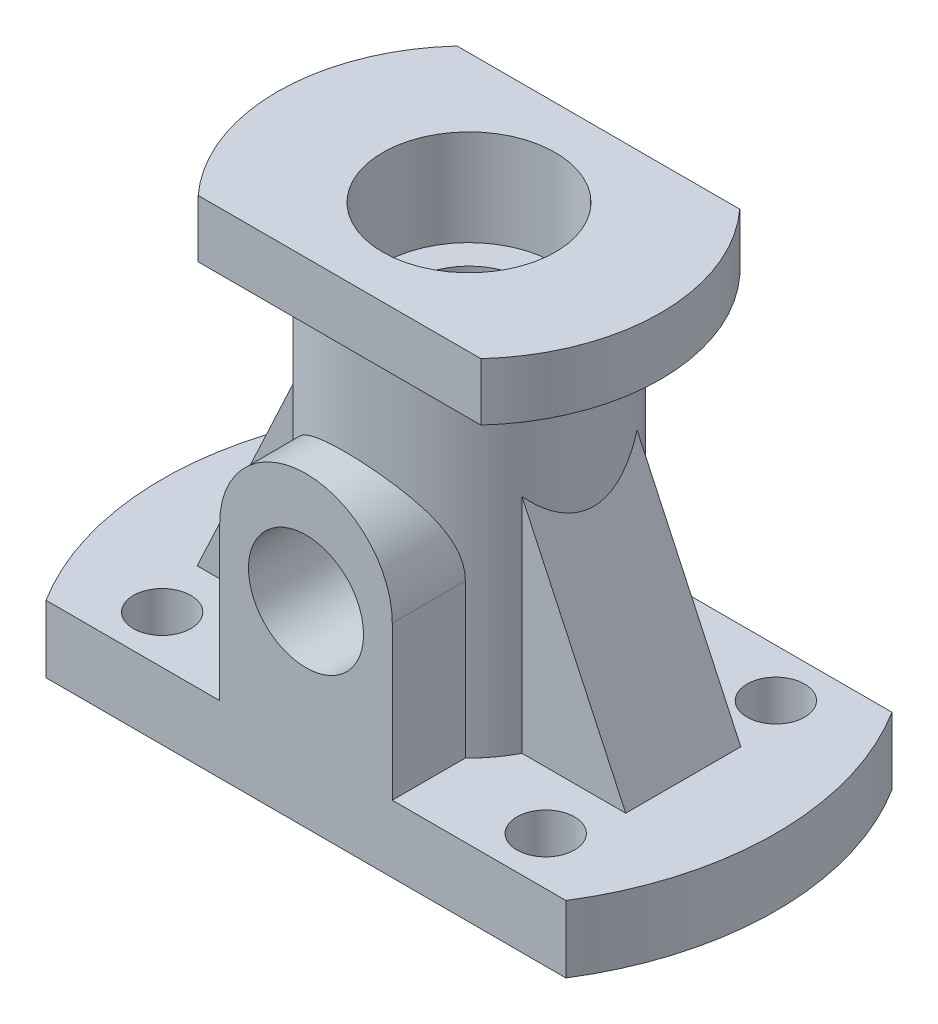
from build123d import *

# Parameters (mm, degrees)
EXTRUDE_1_DEPTH          = 7
SKETCH_2_R               = 3
CUT_EXTRUDE_1_DEPTH      = 8
MIRROR_2_COPY_1_SKETCH_R = 3
MIRROR_2_COPY_1_DEPTH    = 8
SKETCH_3_R               = 13
EXTRUDE_2_DEPTH          = 35
EXTRUDE_3_DEPTH          = 6
SKETCH_5_R               = 9
CUT_EXTRUDE_2_DEPTH      = 10
SKETCH_6_R               = 6
CUT_EXTRUDE_3_DEPTH      = 39
EXTRUDE_4_REACH          = 36
CUT_EXTRUDE_4_REACH      = 36
SKETCH_8_R               = 6
EXTRUDE_6_DEPTH          = 6


with BuildPart() as part:
    # 草图1 → 凸台-拉伸1 (new body)
    with BuildSketch(Plane(origin=(0, 0, 0), x_dir=(1, 0, 0), z_dir=(0, 1, 0))):
        with BuildLine():
            Line((-27.110883423, 17), (27.110883423, 17))
            ThreePointArc((27.110883423, 17), (32, 0), (27.110883423, -17))
            Line((27.110883423, -17), (-27.110883423, -17))
            ThreePointArc((-27.110883423, -17), (-32, 0), (-27.110883423, 17))
        make_face()
    extrude(amount=EXTRUDE_1_DEPTH)

    # 草图2 → 切除-拉伸1 (cut, through all)
    with BuildSketch(Plane(origin=(0, 7, 0), x_dir=(1, 0, 0), z_dir=(0, 1, 0))):
        with Locations((-20, -12)):
            Circle(SKETCH_2_R)
    cut_extrude_1 = extrude(amount=-CUT_EXTRUDE_1_DEPTH, mode=Mode.SUBTRACT)

    # 镜向1: 切除-拉伸1 across plane
    add(cut_extrude_1.mirror(Plane(origin=(0, 0, 0), x_dir=(0, 0, 1), z_dir=(1, 0, 0))), mode=Mode.SUBTRACT)

    # 镜向2: 切除-拉伸1 across plane
    add(cut_extrude_1.mirror(Plane.XY), mode=Mode.SUBTRACT)

    # 镜向2 copy 1 sketch → 镜向2 copy 1 (cut, through all)
    with BuildSketch(Plane(origin=(0, 7, 0), x_dir=(-1, 0, 0), z_dir=(0, 1, 0))):
        with Locations((-20, -12)):
            Circle(MIRROR_2_COPY_1_SKETCH_R)
    extrude(amount=-MIRROR_2_COPY_1_DEPTH, mode=Mode.SUBTRACT)

    # 草图3 → 凸台-拉伸2 (add)
    with BuildSketch(Plane(origin=(0, 7, 0), x_dir=(1, 0, 0), z_dir=(0, 1, 0))):
        Circle(SKETCH_3_R)
    extrude(amount=EXTRUDE_2_DEPTH)

    # 草图4 → 凸台-拉伸3 (add)
    with BuildSketch(Plane(origin=(0, 42, 0), x_dir=(1, 0, 0), z_dir=(0, 1, 0))):
        with BuildLine():
            Line((-14.736938996, 13.5), (14.736938996, 13.5))
            ThreePointArc((14.736938996, 13.5), (19.985679147, 0), (14.736938996, -13.5))
            Line((14.736938996, -13.5), (-14.736938996, -13.5))
            ThreePointArc((-14.736938996, -13.5), (-19.985679147, 0), (-14.736938996, 13.5))
        make_face()
    extrude(amount=EXTRUDE_3_DEPTH)

    # 草图5 → 切除-拉伸2 (cut)
    with BuildSketch(Plane(origin=(0, 48, 0), x_dir=(1, 0, 0), z_dir=(0, 1, 0))):
        Circle(SKETCH_5_R)
    extrude(amount=-CUT_EXTRUDE_2_DEPTH, mode=Mode.SUBTRACT)

    # 草图6 → 切除-拉伸3 (cut, through all)
    with BuildSketch(Plane(origin=(0, 38, 0), x_dir=(1, 0, 0), z_dir=(0, 1, 0))):
        Circle(SKETCH_6_R)
    extrude(amount=-CUT_EXTRUDE_3_DEPTH, mode=Mode.SUBTRACT)

    # 草图7 → 凸台-拉伸4 (add, up to next)
    with BuildSketch(Plane.XY.offset(17), mode=Mode.PRIVATE) as extrude_4_sk1:
        with BuildLine():
            Line((-9, 7), (-9, 23))
            ThreePointArc((-9, 23), (0, 32), (9, 23))
            Line((9, 23), (9, 7))
            Line((9, 7), (-9, 7))
        make_face()
    extrude_4_tool1 = extrude(extrude_4_sk1.sketch, amount=-EXTRUDE_4_REACH, mode=Mode.PRIVATE) - part.part
    add(extrude_4_tool1.solids().sort_by_distance((0, 18.621751, 17))[0])

    # 草图8 → 切除-拉伸4 (cut, up to next)
    with BuildSketch(Plane.XY.offset(17), mode=Mode.PRIVATE) as cut_extrude_4_sk1:
        with Locations((0, 20.461682424)):
            Circle(SKETCH_8_R)
    cut_extrude_4_tool1 = extrude(cut_extrude_4_sk1.sketch, amount=-CUT_EXTRUDE_4_REACH, mode=Mode.PRIVATE) & part.part
    add(cut_extrude_4_tool1.solids().sort_by_distance((0, 20.461682, 17))[0], mode=Mode.SUBTRACT)

    # 草图10 → 凸台-拉伸6 (add, symmetric)
    with BuildSketch(Plane.XY):
        Polygon((-10.493273041, 6.945714178), (-22.343826616, 7), (-14.941545846, 22.874242338), (-10.666084354, 32.042999097), align=None)
    extrude_6 = extrude(amount=EXTRUDE_6_DEPTH, both=True)

    # 镜向4: 凸台-拉伸6 across plane
    add(extrude_6.mirror(Plane(origin=(0, 0, 0), x_dir=(0, 0, 1), z_dir=(1, 0, 0))))


solid = part.part
